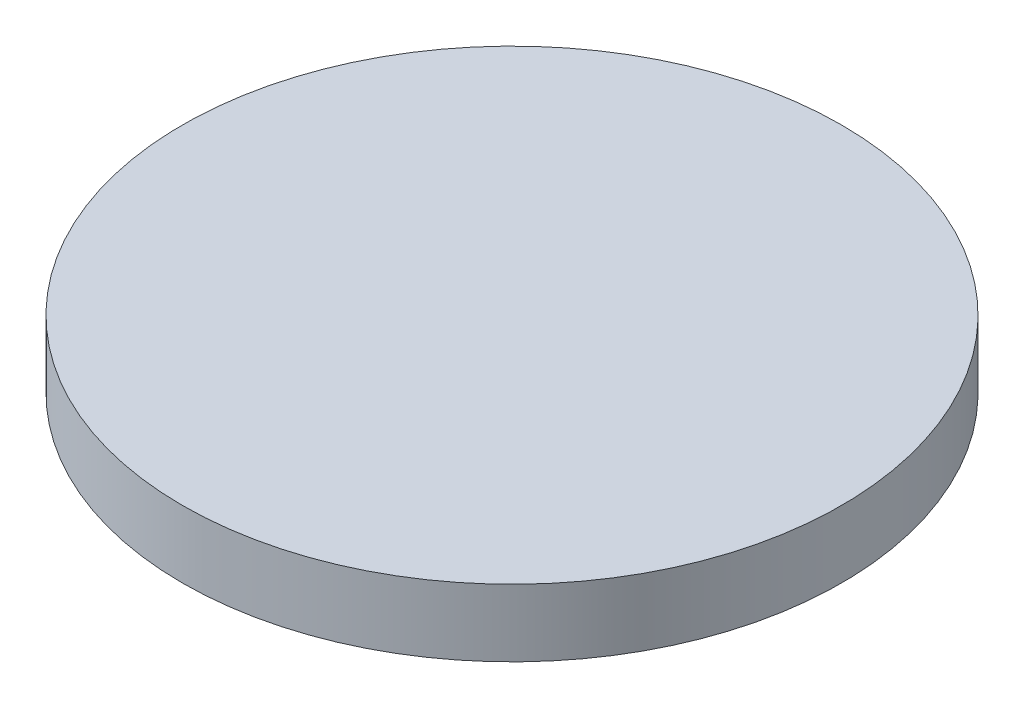
from build123d import *

# Parameters (mm, degrees)
SKETCH1_R           = 9805
BOSS_EXTRUDE1_DEPTH = 1000


with BuildPart() as part:
    # Sketch1 → Boss-Extrude1 (new body, symmetric)
    with BuildSketch(Plane(origin=(0, 0, 0), x_dir=(1, 0, 0), z_dir=(0, 1, 0))):
        Circle(SKETCH1_R)
    extrude(amount=BOSS_EXTRUDE1_DEPTH, both=True)


solid = part.part
